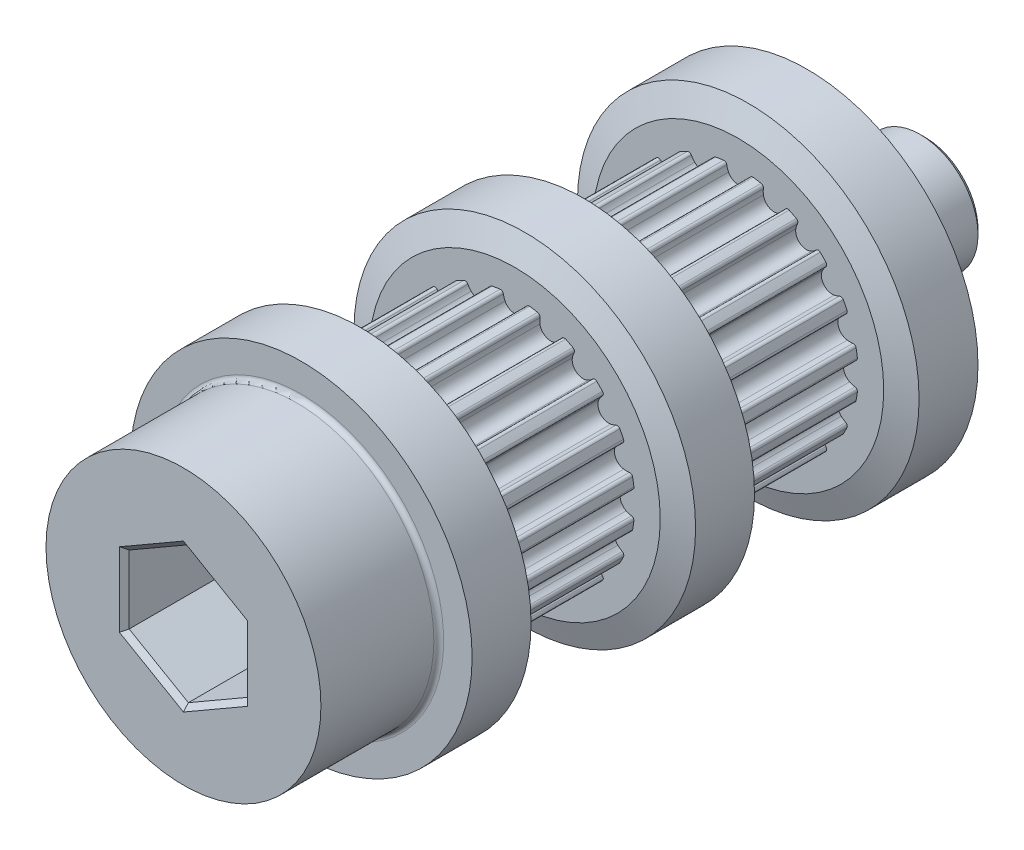
from build123d import *

# Parameters (mm, degrees)
SKETCH10_R          = 7
BOSS_EXTRUDE1_DEPTH = 6
SKETCH13_R          = 2.95
BOSS_EXTRUDE2_DEPTH = 6
CUT_EXTRUDE1_DEPTH  = 3.685
CUT_EXTRUDE3_DEPTH  = 7.37
CIRPATTERN1_COUNT   = 20
CUT_EXTRUDE4_DEPTH  = 7
FILLET1_R           = 0.25
CHAMFER1_SIZE       = 0.25


with BuildPart() as part:
    # Sketch2 → Revolve1 (revolve)
    with BuildSketch(Plane(origin=(0, 0, 0), x_dir=(0, 0, -1), z_dir=(1, 0, 0))):
        Polygon((-3.685, 6.1085), (3.685, 6.1085), (3.685, 7.404), (4.19, 8.6995), (7.19, 8.6995), (7.19, 0), (-18.57, 0), (-18.57, 8.6995), (-15.57, 8.6995), (-15.065, 7.404), (-15.065, 6.1085), (-7.695, 6.1085), (-7.695, 7.404), (-7.19, 8.6995), (-4.19, 8.6995), (-3.685, 7.404), align=None)
    revolve(axis=Axis((0, 0, 18.57), (0, 0, -1)))

    # Sketch10 → Boss-Extrude1 (add)
    with BuildSketch(Plane.XY.offset(18.57)):
        Circle(SKETCH10_R)
    extrude(amount=BOSS_EXTRUDE1_DEPTH)

    # Sketch13 → Boss-Extrude2 (add)
    with BuildSketch(Plane(origin=(0, 0, -7.19), x_dir=(-1, 0, 0), z_dir=(0, 0, -1))):
        Circle(SKETCH13_R)
    extrude(amount=BOSS_EXTRUDE2_DEPTH)

    # Sketch5 → Cut-Extrude1 (cut, symmetric)
    with BuildSketch(Plane.XY):
        with BuildLine():
            Line((2.840989707, 8.6995), (1.896292335, 5.806707124))
            ThreePointArc((1.896292335, 5.806707124), (1.330166224, 5.961914966), (0.751756185, 6.062065233))
            ThreePointArc((0.751756185, 6.062065233), (0.643911332, 6.033664451), (0.58547487, 5.93867868))
            ThreePointArc((0.58547487, 5.93867868), (0.551683777, 5.801420225), (0.498876404, 5.670297753))
            ThreePointArc((0.498876404, 5.670297753), (0, 5.3585), (-0.498876404, 5.670297753))
            ThreePointArc((-0.498876404, 5.670297753), (-0.551683777, 5.801420225), (-0.58547487, 5.93867868))
            ThreePointArc((-0.58547487, 5.93867868), (-0.643911332, 6.033664451), (-0.751756185, 6.062065233))
            ThreePointArc((-0.751756185, 6.062065233), (-1.330166224, 5.961914966), (-1.896292335, 5.806707124))
            Line((-1.896292335, 5.806707124), (-2.840989707, 8.6995))
            Line((-2.840989707, 8.6995), (2.840989707, 8.6995))
        make_face()
    cut_extrude1 = extrude(amount=CUT_EXTRUDE1_DEPTH, both=True, mode=Mode.SUBTRACT)

    # Sketch7 → Cut-Extrude3 (cut)
    with BuildSketch(Plane.XY.offset(7.695)):
        with BuildLine():
            Line((1.896292335, 5.806707124), (2.840989707, 8.6995))
            Line((2.840989707, 8.6995), (-2.840989707, 8.6995))
            Line((-2.840989707, 8.6995), (-1.896292335, 5.806707124))
            ThreePointArc((-1.896292335, 5.806707124), (-1.330166224, 5.961914966), (-0.751756185, 6.062065233))
            ThreePointArc((-0.751756185, 6.062065233), (-0.643911332, 6.033664451), (-0.58547487, 5.93867868))
            ThreePointArc((-0.58547487, 5.93867868), (-0.551683777, 5.801420225), (-0.498876404, 5.670297753))
            ThreePointArc((-0.498876404, 5.670297753), (0, 5.3585), (0.498876404, 5.670297753))
            ThreePointArc((0.498876404, 5.670297753), (0.551683777, 5.801420225), (0.58547487, 5.93867868))
            ThreePointArc((0.58547487, 5.93867868), (0.643911332, 6.033664451), (0.751756185, 6.062065233))
            ThreePointArc((0.751756185, 6.062065233), (1.330166224, 5.961914966), (1.896292335, 5.806707124))
        make_face()
    cut_extrude3 = extrude(amount=CUT_EXTRUDE3_DEPTH, mode=Mode.SUBTRACT)

    # CirPattern1: Cut-Extrude1, Cut-Extrude3 ×20 about axis
    cirpattern1_axis = Axis((0, 0, 0), (0, 0, 1))
    for i in range(1, CIRPATTERN1_COUNT):
        add(cut_extrude1.rotate(cirpattern1_axis, i * 360 / CIRPATTERN1_COUNT), mode=Mode.SUBTRACT)
        add(cut_extrude3.rotate(cirpattern1_axis, i * 360 / CIRPATTERN1_COUNT), mode=Mode.SUBTRACT)

    # Sketch11 → Cut-Extrude4 (cut, through all)
    with BuildSketch(Plane.XY.offset(18.57)):
        Polygon((0, 3.481422123), (-3.015, 1.740711062), (-3.015, -1.740711062), (0, -3.481422123), (3.015, -1.740711062), (3.015, 1.740711062), align=None)
    extrude(amount=CUT_EXTRUDE4_DEPTH, mode=Mode.SUBTRACT)

    # Fillet1
    fillet1_edges = [part.edges().sort_by_distance(p)[0] for p in [
        (-7, 0, 18.57),
        (2.95, 0, -7.19),
    ]]
    fillet(fillet1_edges, radius=FILLET1_R)

    # Chamfer1
    chamfer1_edges = [part.edges().sort_by_distance(p)[0] for p in [
        (1.5075, 2.611066592, 24.57),
        (-1.5075, 2.611066592, 24.57),
        (-3.015, 0, 24.57),
        (-1.5075, -2.611066592, 24.57),
        (1.5075, -2.611066592, 24.57),
        (3.015, 0, 24.57),
        (2.95, 0, -13.19),
    ]]
    chamfer(chamfer1_edges, length=CHAMFER1_SIZE)


solid = part.part
